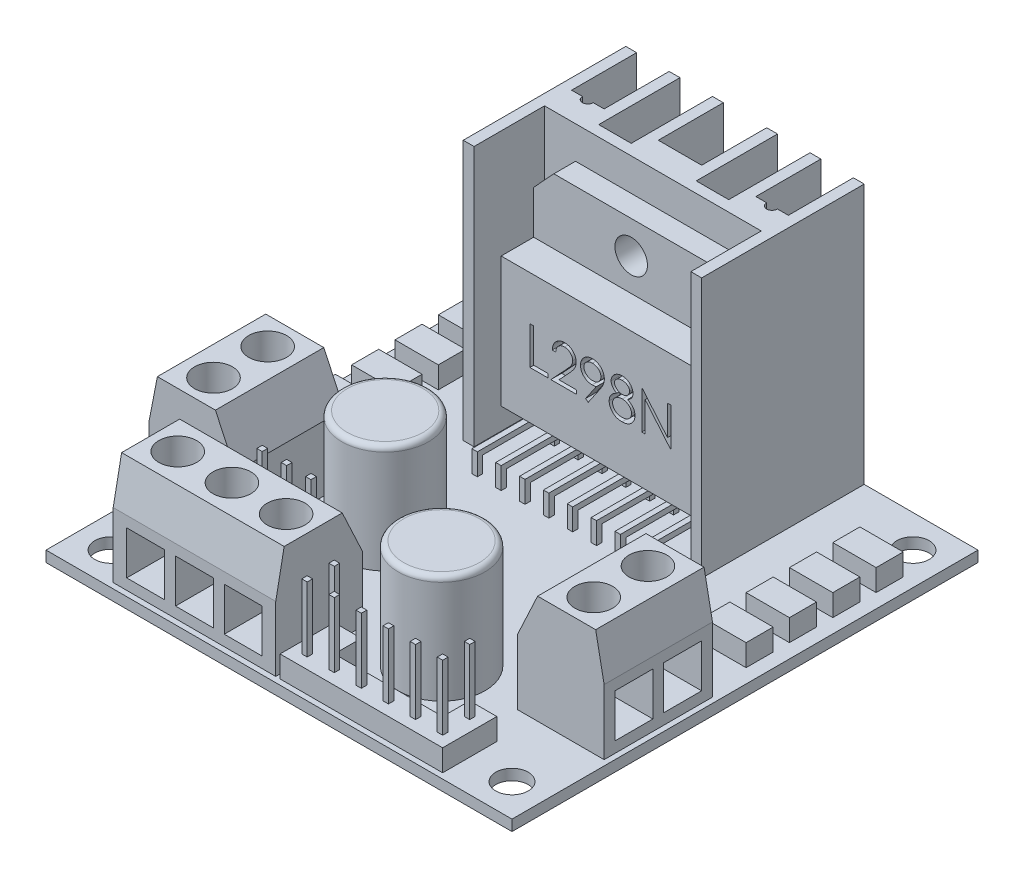
from build123d import *

# Parameters (mm, degrees)
BASE_SKETCH_W             = 43
BASE_SKETCH_H             = 43
BASE_SKETCH_R             = 1.5
BASE_DEPTH                = 1
RADIATOR_DEPTH            = 24
TERMINAL_1_SKETCH_W       = 8
TERMINAL_1_SKETCH_H       = 10
TERMINAL_1_DEPTH          = 10
TERMINAL_2_SKETCH_W       = 15
TERMINAL_2_SKETCH_H       = 8
TERMINAL_2_DEPTH          = 10
CHAMFER_25_SIZE2          = 1.865230633
CHAMFER_25_SIZE           = 4
CHAMFER_10_SIZE           = 4
CHAMFER_10_SIZE2          = 0.777521237
CHAMFER_10_PART_2_SIZE    = 4
CHAMFER_10_PART_2_SIZE2   = 0.777521237
CHAMFER_10_PART_3_SIZE    = 4
CHAMFER_10_PART_3_SIZE2   = 0.777521237
DIODE_SKETCH_W            = 4
DIODE_SKETCH_H            = 2.5
DIODE_DEPTH               = 2
CAPACITOR_SKETCH_R        = 4
CAPACITOR_DEPTH           = 10
FILLET_2_R                = 0.5
RAIL_6_DEPTH              = 2
RAIL_3_SKETCH_W           = 6.6
RAIL_3_SKETCH_H           = 2.2
RAIL_3_DEPTH              = 2
JACK_6_SKETCH_W           = 0.5
JACK_6_SKETCH_H           = 0.5
JACK_6_DEPTH              = 6
JACK_3_SKETCH_W           = 0.5
JACK_3_SKETCH_H           = 0.5
JACK_3_DEPTH              = 6
L298_IC_DEPTH             = 5
L298_CUT_SKETCH_W         = 18
L298_CUT_SKETCH_H         = 6
L298_CUT_DEPTH            = 3
L298_LEG_1_SKETCH_W       = 0.5
L298_LEG_1_SKETCH_H       = 0.5
L298_LEG_1_DEPTH          = 1.5
L298_LEG_2_SKETCH_W       = 0.5
L298_LEG_2_SKETCH_H       = 0.5
L298_LEG_2_DEPTH          = 6
L298_LEG_3_SKETCH_W       = 0.5
L298_LEG_3_SKETCH_H       = 0.5
L298_LEG_3_DEPTH          = 2.5
BOSS_EXTRUDE1_REACH       = 26
SKETCH1_W                 = 0.5
SKETCH1_H                 = 0.5
L298_NAME_DEPTH           = 1
ROLE_SKETCH_R             = 1.5
ROLE_DEPTH                = 11.5
ROLE_TERMINAL_1A_SKETCH_W = 3.5
ROLE_TERMINAL_1A_SKETCH_H = 4
ROLE_TERMINAL_1A_DEPTH    = 4
ROLE_TERMINAL_1B_SKETCH_W = 3.5
ROLE_TERMINAL_1B_SKETCH_H = 4
ROLE_TERMINAL_1B_DEPTH    = 3.5
ROLE_TERMINAL_2_SKETCH_W  = 3.5
ROLE_TERMINAL_2_SKETCH_H  = 4
ROLE_TERMINAL_2_DEPTH     = 3.5
SKETCH4_R                 = 1.75
ROLE_TERMINAL_3_DEPTH     = 3.5


with BuildPart() as part:
    # base_sketch → base (new body)
    with BuildSketch(Plane(origin=(0, 0, 0), x_dir=(1, 0, 0), z_dir=(0, 1, 0))):
        with Locations((-21.5, -21.5)):
            Rectangle(BASE_SKETCH_W, BASE_SKETCH_H)
        with Locations((-40, -3)):
            Circle(BASE_SKETCH_R, mode=Mode.SUBTRACT)
        with Locations((-3, -3)):
            Circle(BASE_SKETCH_R, mode=Mode.SUBTRACT)
        with Locations((-40, -40)):
            Circle(BASE_SKETCH_R, mode=Mode.SUBTRACT)
        with Locations((-3, -40)):
            Circle(BASE_SKETCH_R, mode=Mode.SUBTRACT)
    extrude(amount=BASE_DEPTH)

    # radiator_sketch → radiator (add)
    with BuildSketch(Plane(origin=(0, 1, 0), x_dir=(-1, 0, 0), z_dir=(0, 1, 0))):
        with BuildLine():
            Line((10.5, 0), (10.5, 15))
            Line((10.5, 15), (11.5, 15))
            Line((11.5, 15), (11.5, 8.5))
            Line((11.5, 8.5), (31.5, 8.5))
            Line((31.5, 8.5), (31.5, 15))
            Line((31.5, 15), (32.5, 15))
            Line((32.5, 15), (32.5, 0))
            Line((32.5, 0), (31.5, 0))
            Line((31.5, 0), (31.5, 6))
            Line((31.5, 6), (30.5, 6))
            ThreePointArc((30.5, 6), (30, 6.5), (29.5, 6))
            Line((29.5, 6), (28.5, 6))
            Line((28.5, 6), (28.5, 0))
            Line((28.5, 0), (27.5, 0))
            Line((27.5, 0), (27.5, 7.5))
            Line((27.5, 7.5), (24.5, 7.5))
            Line((24.5, 7.5), (24.5, 0))
            Line((24.5, 0), (23.5, 0))
            Line((23.5, 0), (23.5, 6))
            Line((23.5, 6), (19.5, 6))
            Line((19.5, 6), (19.5, 0))
            Line((19.5, 0), (18.5, 0))
            Line((18.5, 0), (18.5, 7.5))
            Line((18.5, 7.5), (15.5, 7.5))
            Line((15.5, 7.5), (15.5, 0))
            Line((15.5, 0), (14.5, 0))
            Line((14.5, 0), (14.5, 6))
            Line((14.5, 6), (13.5, 6))
            ThreePointArc((13.5, 6), (13, 6.5), (12.5, 6))
            Line((12.5, 6), (11.5, 6))
            Line((11.5, 6), (11.5, 0))
            Line((11.5, 0), (10.5, 0))
        make_face()
    extrude(amount=RADIATOR_DEPTH)

    # terminal_1_sketch → terminal_1 (add)
    with BuildSketch(Plane(origin=(0, 1, 0), x_dir=(-1, 0, 0), z_dir=(0, 1, 0))):
        with Locations((4.5, 29)):
            Rectangle(TERMINAL_1_SKETCH_W, TERMINAL_1_SKETCH_H)
        with Locations((38.5, 29)):
            Rectangle(TERMINAL_1_SKETCH_W, TERMINAL_1_SKETCH_H)
    extrude(amount=TERMINAL_1_DEPTH)

    # terminal_2_sketch → terminal_2 (add)
    with BuildSketch(Plane(origin=(0, 1, 0), x_dir=(-1, 0, 0), z_dir=(0, 1, 0))):
        with Locations((29.8, 38.5)):
            Rectangle(TERMINAL_2_SKETCH_W, TERMINAL_2_SKETCH_H)
    extrude(amount=TERMINAL_2_DEPTH)

    # chamfer_25
    chamfer_25_edges = [part.edges().sort_by_distance(p)[0] for p in [
        (-34.5, 11, 29),
        (-8.5, 11, 29),
        (-29.8, 11, 34.5),
    ]]
    chamfer(chamfer_25_edges, length=CHAMFER_25_SIZE, length2=CHAMFER_25_SIZE2)

    # chamfer_10
    chamfer_10_edges = [part.edges().sort_by_distance(p)[0] for p in [
        (-42.5, 11, 29),
    ]]
    chamfer_10_side = [part.faces().sort_by_distance(p)[0] for p in [
        (-42.5, 6, 29),
    ]]
    chamfer(chamfer_10_edges, length=CHAMFER_10_SIZE, length2=CHAMFER_10_SIZE2, reference=chamfer_10_side[0])

    # chamfer_10 part 2
    chamfer_10_part_2_edges = [part.edges().sort_by_distance(p)[0] for p in [
        (-0.5, 11, 29),
    ]]
    chamfer_10_part_2_side = [part.faces().sort_by_distance(p)[0] for p in [
        (-0.5, 6, 29),
    ]]
    chamfer(chamfer_10_part_2_edges, length=CHAMFER_10_PART_2_SIZE, length2=CHAMFER_10_PART_2_SIZE2, reference=chamfer_10_part_2_side[0])

    # chamfer_10 part 3
    chamfer_10_part_3_edges = [part.edges().sort_by_distance(p)[0] for p in [
        (-29.8, 11, 42.5),
    ]]
    chamfer_10_part_3_side = [part.faces().sort_by_distance(p)[0] for p in [
        (-29.8, 6, 42.5),
    ]]
    chamfer(chamfer_10_part_3_edges, length=CHAMFER_10_PART_3_SIZE, length2=CHAMFER_10_PART_3_SIZE2, reference=chamfer_10_part_3_side[0])

    # diode_sketch → diode (add)
    with BuildSketch(Plane(origin=(0, 1, 0), x_dir=(-1, 0, 0), z_dir=(0, 1, 0))):
        with Locations((3.3, 10.85)):
            Rectangle(DIODE_SKETCH_W, DIODE_SKETCH_H)
        with Locations((3.3, 6.85)):
            Rectangle(DIODE_SKETCH_W, DIODE_SKETCH_H)
        with Locations((3.3, 14.85)):
            Rectangle(DIODE_SKETCH_W, DIODE_SKETCH_H)
        with Locations((3.3, 18.85)):
            Rectangle(DIODE_SKETCH_W, DIODE_SKETCH_H)
        with Locations((39.7, 18.85)):
            Rectangle(DIODE_SKETCH_W, DIODE_SKETCH_H)
        with Locations((39.7, 14.85)):
            Rectangle(DIODE_SKETCH_W, DIODE_SKETCH_H)
        with Locations((39.7, 10.85)):
            Rectangle(DIODE_SKETCH_W, DIODE_SKETCH_H)
        with Locations((39.7, 6.85)):
            Rectangle(DIODE_SKETCH_W, DIODE_SKETCH_H)
    extrude(amount=DIODE_DEPTH)

    # capacitor_sketch → capacitor (add)
    with BuildSketch(Plane(origin=(0, 1, 0), x_dir=(-1, 0, 0), z_dir=(0, 1, 0))):
        with Locations((28.5, 26.2)):
            Circle(CAPACITOR_SKETCH_R)
        with Locations((15.5, 34)):
            Circle(CAPACITOR_SKETCH_R)
    extrude(amount=CAPACITOR_DEPTH)

    # fillet 2
    fillet_2_edges = [part.edges().sort_by_distance(p)[0] for p in [
        (-24.5, 11, 26.2),
        (-11.5, 11, 34),
    ]]
    fillet(fillet_2_edges, radius=FILLET_2_R)

    # rail_6_sketch → rail_6 (add)
    with BuildSketch(Plane(origin=(0, 1, 0), x_dir=(-1, 0, 0), z_dir=(0, 1, 0))):
        Polygon((21.9, 42.5), (6.9, 42.5), (6.9, 37.5), (9.4, 37.5), (9.4, 40), (19.4, 40), (19.4, 37.5), (21.9, 37.5), align=None)
    extrude(amount=RAIL_6_DEPTH)

    # rail_3_sketch → rail_3 (add)
    with BuildSketch(Plane(origin=(0, 1, 0), x_dir=(-1, 0, 0), z_dir=(0, 1, 0))):
        with Locations((30.9, 32.9)):
            Rectangle(RAIL_3_SKETCH_W, RAIL_3_SKETCH_H)
    extrude(amount=RAIL_3_DEPTH)

    # jack_6_sketch → jack_6 (add)
    with BuildSketch(Plane(origin=(0, 3, 0), x_dir=(-1, 0, 0), z_dir=(0, 1, 0))):
        with Locations((18.15, 41.25)):
            Rectangle(JACK_6_SKETCH_W, JACK_6_SKETCH_H)
        with Locations((20.65, 41.25)):
            Rectangle(JACK_6_SKETCH_W, JACK_6_SKETCH_H)
        with Locations((15.65, 41.25)):
            Rectangle(JACK_6_SKETCH_W, JACK_6_SKETCH_H)
        with Locations((13.15, 41.25)):
            Rectangle(JACK_6_SKETCH_W, JACK_6_SKETCH_H)
        with Locations((10.65, 41.25)):
            Rectangle(JACK_6_SKETCH_W, JACK_6_SKETCH_H)
        with Locations((8.15, 41.25)):
            Rectangle(JACK_6_SKETCH_W, JACK_6_SKETCH_H)
        with Locations((20.65, 38.75)):
            Rectangle(JACK_6_SKETCH_W, JACK_6_SKETCH_H)
        with Locations((8.15, 38.75)):
            Rectangle(JACK_6_SKETCH_W, JACK_6_SKETCH_H)
    extrude(amount=JACK_6_DEPTH)

    # jack_3_sketch → jack_3 (add)
    with BuildSketch(Plane(origin=(0, 3, 0), x_dir=(1, 0, 0), z_dir=(0, 1, 0))):
        with Locations((-30.9, -32.9)):
            Rectangle(JACK_3_SKETCH_W, JACK_3_SKETCH_H)
        with Locations((-33.15, -32.9)):
            Rectangle(JACK_3_SKETCH_W, JACK_3_SKETCH_H)
        with Locations((-28.65, -32.9)):
            Rectangle(JACK_3_SKETCH_W, JACK_3_SKETCH_H)
    extrude(amount=JACK_3_DEPTH)

    # L298_sketch → L298_IC (add)
    with BuildSketch(Plane.XY.offset(8.5)):
        Polygon((-30.5, 19.987466442), (-30.5, 4), (-12.5, 4), (-12.5, 19.987466442), (-14.362533558, 22), (-28.637466442, 22), align=None)
    extrude(amount=L298_IC_DEPTH)

    # L298_cut_sketch → L298_cut (cut)
    with BuildSketch(Plane.XY.offset(13.5)):
        with Locations((-21.5, 19)):
            Rectangle(L298_CUT_SKETCH_W, L298_CUT_SKETCH_H)
    extrude(amount=-L298_CUT_DEPTH, mode=Mode.SUBTRACT)

    # L298_leg_1_sketch → L298_leg_1 (add)
    with BuildSketch(Plane.XZ.offset(-4)):
        with Locations((-28.1, 11)):
            Rectangle(L298_LEG_1_SKETCH_W, L298_LEG_1_SKETCH_H)
        with Locations((-29.2, 11)):
            Rectangle(L298_LEG_1_SKETCH_W, L298_LEG_1_SKETCH_H)
        with Locations((-27, 11)):
            Rectangle(L298_LEG_1_SKETCH_W, L298_LEG_1_SKETCH_H)
        with Locations((-25.9, 11)):
            Rectangle(L298_LEG_1_SKETCH_W, L298_LEG_1_SKETCH_H)
        with Locations((-24.8, 11)):
            Rectangle(L298_LEG_1_SKETCH_W, L298_LEG_1_SKETCH_H)
        with Locations((-23.7, 11)):
            Rectangle(L298_LEG_1_SKETCH_W, L298_LEG_1_SKETCH_H)
        with Locations((-22.6, 11)):
            Rectangle(L298_LEG_1_SKETCH_W, L298_LEG_1_SKETCH_H)
        with Locations((-21.5, 11)):
            Rectangle(L298_LEG_1_SKETCH_W, L298_LEG_1_SKETCH_H)
        with Locations((-20.4, 11)):
            Rectangle(L298_LEG_1_SKETCH_W, L298_LEG_1_SKETCH_H)
        with Locations((-19.3, 11)):
            Rectangle(L298_LEG_1_SKETCH_W, L298_LEG_1_SKETCH_H)
        with Locations((-18.2, 11)):
            Rectangle(L298_LEG_1_SKETCH_W, L298_LEG_1_SKETCH_H)
        with Locations((-17.1, 11)):
            Rectangle(L298_LEG_1_SKETCH_W, L298_LEG_1_SKETCH_H)
        with Locations((-16, 11)):
            Rectangle(L298_LEG_1_SKETCH_W, L298_LEG_1_SKETCH_H)
        with Locations((-14.9, 11)):
            Rectangle(L298_LEG_1_SKETCH_W, L298_LEG_1_SKETCH_H)
        with Locations((-13.8, 11)):
            Rectangle(L298_LEG_1_SKETCH_W, L298_LEG_1_SKETCH_H)
    extrude(amount=L298_LEG_1_DEPTH)

    # L298_leg_2_sketch → L298_leg_2 (add)
    with BuildSketch(Plane.XY.offset(11.25)):
        with Locations((-13.8, 2.75)):
            Rectangle(L298_LEG_2_SKETCH_W, L298_LEG_2_SKETCH_H)
        with Locations((-16, 2.75)):
            Rectangle(L298_LEG_2_SKETCH_W, L298_LEG_2_SKETCH_H)
        with Locations((-18.2, 2.75)):
            Rectangle(L298_LEG_2_SKETCH_W, L298_LEG_2_SKETCH_H)
        with Locations((-20.4, 2.75)):
            Rectangle(L298_LEG_2_SKETCH_W, L298_LEG_2_SKETCH_H)
        with Locations((-22.6, 2.75)):
            Rectangle(L298_LEG_2_SKETCH_W, L298_LEG_2_SKETCH_H)
        with Locations((-24.8, 2.75)):
            Rectangle(L298_LEG_2_SKETCH_W, L298_LEG_2_SKETCH_H)
        with Locations((-27, 2.75)):
            Rectangle(L298_LEG_2_SKETCH_W, L298_LEG_2_SKETCH_H)
        with Locations((-29.2, 2.75)):
            Rectangle(L298_LEG_2_SKETCH_W, L298_LEG_2_SKETCH_H)
    extrude(amount=L298_LEG_2_DEPTH)

    # L298_leg_3_sketch → L298_leg_3 (add)
    with BuildSketch(Plane.XZ):
        with Locations((-29.2, 17)):
            Rectangle(L298_LEG_3_SKETCH_W, L298_LEG_3_SKETCH_H)
        with Locations((-27, 17)):
            Rectangle(L298_LEG_3_SKETCH_W, L298_LEG_3_SKETCH_H)
        with Locations((-24.8, 17)):
            Rectangle(L298_LEG_3_SKETCH_W, L298_LEG_3_SKETCH_H)
        with Locations((-22.6, 17)):
            Rectangle(L298_LEG_3_SKETCH_W, L298_LEG_3_SKETCH_H)
        with Locations((-20.4, 17)):
            Rectangle(L298_LEG_3_SKETCH_W, L298_LEG_3_SKETCH_H)
        with Locations((-18.2, 17)):
            Rectangle(L298_LEG_3_SKETCH_W, L298_LEG_3_SKETCH_H)
        with Locations((-16, 17)):
            Rectangle(L298_LEG_3_SKETCH_W, L298_LEG_3_SKETCH_H)
        with Locations((-13.8, 17)):
            Rectangle(L298_LEG_3_SKETCH_W, L298_LEG_3_SKETCH_H)
    extrude(amount=-L298_LEG_3_DEPTH)

    # Sketch1 → Boss-Extrude1 (add, up to next)
    with BuildSketch(Plane(origin=(0, 1, 0), x_dir=(1, 0, 0), z_dir=(0, 1, 0)), mode=Mode.PRIVATE) as boss_extrude1_sk1:
        with Locations((-14.9, -11)):
            Rectangle(SKETCH1_W, SKETCH1_H)
    boss_extrude1_tool1 = extrude(boss_extrude1_sk1.sketch, amount=BOSS_EXTRUDE1_REACH, mode=Mode.PRIVATE) - part.part
    add(boss_extrude1_tool1.solids().sort_by_distance((-14.9, 1, 11))[0])
    # Sketch1 → Boss-Extrude1 (add, up to next)
    with BuildSketch(Plane(origin=(0, 1, 0), x_dir=(1, 0, 0), z_dir=(0, 1, 0)), mode=Mode.PRIVATE) as boss_extrude1_sk2:
        with Locations((-17.1, -11)):
            Rectangle(SKETCH1_W, SKETCH1_H)
    boss_extrude1_tool2 = extrude(boss_extrude1_sk2.sketch, amount=BOSS_EXTRUDE1_REACH, mode=Mode.PRIVATE) - part.part
    add(boss_extrude1_tool2.solids().sort_by_distance((-17.1, 1, 11))[0])
    # Sketch1 → Boss-Extrude1 (add, up to next)
    with BuildSketch(Plane(origin=(0, 1, 0), x_dir=(1, 0, 0), z_dir=(0, 1, 0)), mode=Mode.PRIVATE) as boss_extrude1_sk3:
        with Locations((-19.3, -11)):
            Rectangle(SKETCH1_W, SKETCH1_H)
    boss_extrude1_tool3 = extrude(boss_extrude1_sk3.sketch, amount=BOSS_EXTRUDE1_REACH, mode=Mode.PRIVATE) - part.part
    add(boss_extrude1_tool3.solids().sort_by_distance((-19.3, 1, 11))[0])
    # Sketch1 → Boss-Extrude1 (add, up to next)
    with BuildSketch(Plane(origin=(0, 1, 0), x_dir=(1, 0, 0), z_dir=(0, 1, 0)), mode=Mode.PRIVATE) as boss_extrude1_sk4:
        with Locations((-21.5, -11)):
            Rectangle(SKETCH1_W, SKETCH1_H)
    boss_extrude1_tool4 = extrude(boss_extrude1_sk4.sketch, amount=BOSS_EXTRUDE1_REACH, mode=Mode.PRIVATE) - part.part
    add(boss_extrude1_tool4.solids().sort_by_distance((-21.5, 1, 11))[0])
    # Sketch1 → Boss-Extrude1 (add, up to next)
    with BuildSketch(Plane(origin=(0, 1, 0), x_dir=(1, 0, 0), z_dir=(0, 1, 0)), mode=Mode.PRIVATE) as boss_extrude1_sk5:
        with Locations((-23.7, -11)):
            Rectangle(SKETCH1_W, SKETCH1_H)
    boss_extrude1_tool5 = extrude(boss_extrude1_sk5.sketch, amount=BOSS_EXTRUDE1_REACH, mode=Mode.PRIVATE) - part.part
    add(boss_extrude1_tool5.solids().sort_by_distance((-23.7, 1, 11))[0])
    # Sketch1 → Boss-Extrude1 (add, up to next)
    with BuildSketch(Plane(origin=(0, 1, 0), x_dir=(1, 0, 0), z_dir=(0, 1, 0)), mode=Mode.PRIVATE) as boss_extrude1_sk6:
        with Locations((-25.9, -11)):
            Rectangle(SKETCH1_W, SKETCH1_H)
    boss_extrude1_tool6 = extrude(boss_extrude1_sk6.sketch, amount=BOSS_EXTRUDE1_REACH, mode=Mode.PRIVATE) - part.part
    add(boss_extrude1_tool6.solids().sort_by_distance((-25.9, 1, 11))[0])
    # Sketch1 → Boss-Extrude1 (add, up to next)
    with BuildSketch(Plane(origin=(0, 1, 0), x_dir=(1, 0, 0), z_dir=(0, 1, 0)), mode=Mode.PRIVATE) as boss_extrude1_sk7:
        with Locations((-28.1, -11)):
            Rectangle(SKETCH1_W, SKETCH1_H)
    boss_extrude1_tool7 = extrude(boss_extrude1_sk7.sketch, amount=BOSS_EXTRUDE1_REACH, mode=Mode.PRIVATE) - part.part
    add(boss_extrude1_tool7.solids().sort_by_distance((-28.1, 1, 11))[0])

    # L298_name_sketch → L298_name (cut)
    with BuildSketch(Plane.XY.offset(13.5)):
        Polygon((-27.846931762, 11.915865738), (-27.532829198, 11.915865738), (-27.532829198, 8.774840097), (-26.186675351, 8.774840097), (-26.186675351, 8.415865738), (-27.846931762, 8.415865738), align=None)
        with BuildLine():
            Line((-25.468726633, 10.838942661), (-25.782829198, 10.838942661))
            add(Edge.make_bspline(
                [(-25.782829198, 10.838942661), (-25.780782045, 10.880613549), (-25.77676149, 10.962454063), (-25.757933201, 11.08177797), (-25.730992324, 11.195832768), (-25.69290087, 11.303702682), (-25.645594592, 11.40634149), (-25.588864565, 11.503341505), (-25.521670714, 11.594332694), (-25.44546398, 11.678471537), (-25.362695341, 11.755659108), (-25.273389402, 11.822314351), (-25.179544374, 11.878632022), (-25.081444976, 11.925713264), (-24.977984412, 11.96105311), (-24.870101554, 11.98727475), (-24.757322418, 12.003051095), (-24.680482396, 12.004746881), (-24.641402915, 12.005609328)],
                knots=[0, 0, 0, 0, 0.000125083, 0.00024566, 0.000361805, 0.000476223, 0.000588214, 0.000700404, 0.000812728, 0.00092691, 0.001040529, 0.001151727, 0.001260545, 0.001368429, 0.001477521, 0.001587884, 0.001701119, 0.00181831, 0.00181831, 0.00181831, 0.00181831], degree=3))
            add(Edge.make_bspline(
                [(-24.641402915, 12.005609328), (-24.603024841, 12.004710871), (-24.527613297, 12.002945436), (-24.417551282, 11.987784407), (-24.312773988, 11.964038815), (-24.213486221, 11.930723399), (-24.120480157, 11.885938972), (-24.033057112, 11.832141433), (-23.950176301, 11.769921602), (-23.875569518, 11.696667788), (-23.807061439, 11.618465404), (-23.747959183, 11.5349775), (-23.69734602, 11.448748214), (-23.65515834, 11.359120013), (-23.624102201, 11.265248985), (-23.600523993, 11.168501782), (-23.587196579, 11.067876971), (-23.585151156, 10.999770415), (-23.584111249, 10.965144584)],
                knots=[0, 0, 0, 0, 0.000115089, 0.000226145, 0.000332614, 0.000437044, 0.000539592, 0.000641561, 0.000744629, 0.00084975, 0.000954621, 0.001056175, 0.001156101, 0.001254284, 0.001352726, 0.001452208, 0.001552655, 0.001656537, 0.001656537, 0.001656537, 0.001656537], degree=3))
            add(Edge.make_bspline(
                [(-23.584111249, 10.965144584), (-23.585804512, 10.916396749), (-23.589161323, 10.819756536), (-23.6178757, 10.677741673), (-23.662722211, 10.540148254), (-23.716719568, 10.429410952), (-23.771192012, 10.340177458), (-23.820279519, 10.266708753), (-23.87774433, 10.187603285), (-23.944422828, 10.103125947), (-24.0189357, 10.012615042), (-24.101957864, 9.916125247), (-24.194081346, 9.814653477), (-24.258739846, 9.745347876), (-24.292244262, 9.709435449)],
                knots=[0, 0, 0, 0, 0.000146118, 0.000289672, 0.0004329, 0.00057934, 0.000657978, 0.000746456, 0.000844345, 0.000951219, 0.001069268, 0.00119604, 0.001333047, 0.001480391, 0.001480391, 0.001480391, 0.001480391], degree=3))
            Line((-24.292244262, 9.709435449), (-25.167945383, 8.774840097))
            Line((-25.167945383, 8.774840097), (-23.539239454, 8.774840097))
            Line((-23.539239454, 8.774840097), (-23.539239454, 8.415865738))
            Line((-23.539239454, 8.415865738), (-25.917444582, 8.415865738))
            Line((-25.917444582, 8.415865738), (-24.560072787, 9.864383366))
            add(Edge.make_bspline(
                [(-24.560072787, 9.864383366), (-24.5270249, 9.898881673), (-24.463546673, 9.965145859), (-24.373764097, 10.061888819), (-24.293125108, 10.15163836), (-24.221107715, 10.234224909), (-24.15927421, 10.310856476), (-24.104401978, 10.37905118), (-24.060436387, 10.44180563), (-24.012720991, 10.514546244), (-23.96650701, 10.603358561), (-23.926794654, 10.711892251), (-23.902579806, 10.823619503), (-23.89967497, 10.89912154), (-23.898213813, 10.937099712)],
                knots=[0, 0, 0, 0, 0.000143319, 0.000275286, 0.00039593, 0.000505287, 0.000603949, 0.000691331, 0.000767782, 0.00083371, 0.000952247, 0.001067137, 0.001179618, 0.001293462, 0.001293462, 0.001293462, 0.001293462], degree=3))
            add(Edge.make_bspline(
                [(-23.898213813, 10.937099712), (-23.898849555, 10.960981111), (-23.900102481, 11.008046761), (-23.911160179, 11.07705252), (-23.927870685, 11.143617334), (-23.951815943, 11.207945953), (-23.983422683, 11.269391605), (-24.021896063, 11.328029085), (-24.066286126, 11.38471805), (-24.117637396, 11.437871349), (-24.174048915, 11.486552554), (-24.233643165, 11.529676639), (-24.296693269, 11.56571575), (-24.362933391, 11.595259247), (-24.432178861, 11.618434629), (-24.504563606, 11.634493208), (-24.579887622, 11.644575692), (-24.631321118, 11.645939864), (-24.657528717, 11.646634969)],
                knots=[0, 0, 0, 0, 7.16e-05, 0.00014111, 0.00020913, 0.00027724, 0.000346538, 0.000415963, 0.000487357, 0.000562233, 0.000637292, 0.000710646, 0.000782564, 0.000854749, 0.000927915, 0.001001225, 0.001076884, 0.001155488, 0.001155488, 0.001155488, 0.001155488], degree=3))
            add(Edge.make_bspline(
                [(-24.657528717, 11.646634969), (-24.68489955, 11.645919936), (-24.738651346, 11.644515731), (-24.817570379, 11.634693067), (-24.892856156, 11.617747227), (-24.964698059, 11.594570552), (-25.033217645, 11.565112004), (-25.098081689, 11.528420259), (-25.159144578, 11.484636766), (-25.216521102, 11.434996209), (-25.269385081, 11.379728608), (-25.315831957, 11.318118645), (-25.356415971, 11.25129123), (-25.391825204, 11.179426679), (-25.420580894, 11.101872899), (-25.442554045, 11.018905194), (-25.459940891, 10.930883813), (-25.465749412, 10.870098728), (-25.468726633, 10.838942661)],
                knots=[0, 0, 0, 0, 8.2106e-05, 0.000161243, 0.000238127, 0.000313291, 0.000387401, 0.000461495, 0.000536397, 0.000612445, 0.000688819, 0.000765383, 0.000843422, 0.000923066, 0.001005373, 0.001091093, 0.001180334, 0.001274175, 0.001274175, 0.001274175, 0.001274175], degree=3))
        make_face()
        with BuildLine():
            Line((-22.462316377, 8.326122148), (-22.71331798, 8.500701475))
            Line((-22.71331798, 8.500701475), (-21.740160928, 9.923277597))
            add(Edge.make_bspline(
                [(-21.740160928, 9.923277597), (-21.802251664, 9.915684534), (-21.924511784, 9.900733369), (-22.047648886, 9.897986714), (-22.108249871, 9.896634969)],
                knots=[0, 0, 0, 0, 0.000187529, 0.000369255, 0.000369255, 0.000369255, 0.000369255], degree=3))
            add(Edge.make_bspline(
                [(-22.108249871, 9.896634969), (-22.144991918, 9.897576045), (-22.217113345, 9.899423296), (-22.323144998, 9.914065104), (-22.425030558, 9.936615232), (-22.522499914, 9.970263987), (-22.615919419, 10.012082196), (-22.705085133, 10.06393921), (-22.789877023, 10.124945501), (-22.869384433, 10.194778493), (-22.941696172, 10.271456545), (-23.00611947, 10.352612188), (-23.059660602, 10.439188159), (-23.104137187, 10.529418378), (-23.137867641, 10.624599729), (-23.162430178, 10.723649129), (-23.177552532, 10.827260771), (-23.179351628, 10.897785902), (-23.180265095, 10.933594103)],
                knots=[0, 0, 0, 0, 0.000110185, 0.000216284, 0.000320547, 0.000422759, 0.000525058, 0.000627155, 0.000731643, 0.000837964, 0.0009441, 0.00104747, 0.001148247, 0.001248901, 0.001348697, 0.001450555, 0.001554666, 0.00166205, 0.00166205, 0.00166205, 0.00166205], degree=3))
            add(Edge.make_bspline(
                [(-23.180265095, 10.933594103), (-23.17853066, 10.982562756), (-23.175126317, 11.078678288), (-23.147727799, 11.219112057), (-23.10266746, 11.3518986), (-23.039839083, 11.476688794), (-22.960704362, 11.591687533), (-22.865595772, 11.695296142), (-22.755091807, 11.786040996), (-22.631709788, 11.864045074), (-22.498356768, 11.926780071), (-22.358688109, 11.973019371), (-22.213773989, 12.000218119), (-22.115606319, 12.00380398), (-22.066182563, 12.005609328)],
                knots=[0, 0, 0, 0, 0.000146818, 0.000288173, 0.000427413, 0.000566316, 0.000705952, 0.000844895, 0.000986821, 0.001133677, 0.001281714, 0.001427825, 0.001574003, 0.00172222, 0.00172222, 0.00172222, 0.00172222], degree=3))
            add(Edge.make_bspline(
                [(-22.066182563, 12.005609328), (-22.017694143, 12.003779165), (-21.921885596, 12.000162935), (-21.78099659, 11.973678966), (-21.646055573, 11.929042293), (-21.517810586, 11.867357729), (-21.399071174, 11.790036822), (-21.292295363, 11.697902298), (-21.199919824, 11.590896771), (-21.122095943, 11.471608281), (-21.059625903, 11.343441299), (-21.01455362, 11.209657377), (-20.986807981, 11.071218656), (-20.983311654, 10.977424181), (-20.981547146, 10.930088494)],
                knots=[0, 0, 0, 0, 0.000145418, 0.000287333, 0.000428343, 0.000570713, 0.000713061, 0.00085223, 0.000992387, 0.001135706, 0.001278381, 0.001418948, 0.001558239, 0.001700158, 0.001700158, 0.001700158, 0.001700158], degree=3))
            add(Edge.make_bspline(
                [(-20.981547146, 10.930088494), (-20.982725555, 10.893344727), (-20.985115663, 10.818819186), (-21.00185197, 10.705588844), (-21.030272155, 10.590137614), (-21.062523854, 10.492416018), (-21.093656022, 10.411707569), (-21.122957153, 10.347955989), (-21.155469307, 10.280854725), (-21.193388072, 10.211107387), (-21.234150369, 10.137824852), (-21.280209646, 10.061742137), (-21.330515217, 9.982757144), (-21.366344937, 9.929510056), (-21.384692178, 9.902243943)],
                knots=[0, 0, 0, 0, 0.000110219, 0.000223552, 0.000342587, 0.000466527, 0.000532018, 0.000601997, 0.000676938, 0.00075567, 0.000840114, 0.000928491, 0.001022434, 0.001121023, 0.001121023, 0.001121023, 0.001121023], degree=3))
            Line((-21.384692178, 9.902243943), (-22.462316377, 8.326122148))
        make_face()
        with BuildLine():
            add(Edge.make_bspline(
                [(-22.050056762, 10.255609328), (-22.022222748, 10.256369711), (-21.968039384, 10.25784992), (-21.888662085, 10.266859162), (-21.813737882, 10.282833148), (-21.743066633, 10.30575286), (-21.675939731, 10.333409529), (-21.613423403, 10.368621515), (-21.555465327, 10.41063815), (-21.5016774, 10.457848166), (-21.453913401, 10.510298749), (-21.41137037, 10.565195856), (-21.375209802, 10.622780466), (-21.346646525, 10.683773728), (-21.32316195, 10.746690937), (-21.306943938, 10.812545292), (-21.297959605, 10.880993693), (-21.29642803, 10.927492351), (-21.29564971, 10.951122148)],
                knots=[0, 0, 0, 0, 8.3507e-05, 0.00016256, 0.000239294, 0.000312908, 0.000385178, 0.000456751, 0.000527578, 0.000599603, 0.000671055, 0.000740051, 0.000807755, 0.000874553, 0.000941763, 0.001008931, 0.001077548, 0.001148448, 0.001148448, 0.001148448, 0.001148448], degree=3))
            add(Edge.make_bspline(
                [(-21.29564971, 10.951122148), (-21.29631938, 10.974761813), (-21.297639045, 11.021346673), (-21.308226344, 11.089896413), (-21.326851568, 11.155589674), (-21.351842052, 11.218786104), (-21.38476229, 11.278966476), (-21.424265776, 11.336886348), (-21.471198226, 11.392178475), (-21.525200792, 11.443542459), (-21.583435345, 11.490890358), (-21.645495845, 11.532676434), (-21.710870761, 11.567697631), (-21.779161251, 11.5965966), (-21.8505096, 11.619148376), (-21.924873588, 11.635365741), (-22.002628994, 11.644337495), (-22.05541028, 11.64585939), (-22.082308364, 11.646634969)],
                knots=[0, 0, 0, 0, 7.09e-05, 0.000139717, 0.000207422, 0.000275384, 0.000343146, 0.000412766, 0.000485392, 0.000560268, 0.000636041, 0.000710323, 0.000784354, 0.000858188, 0.000932471, 0.001008519, 0.001086179, 0.001166885, 0.001166885, 0.001166885, 0.001166885], degree=3))
            add(Edge.make_bspline(
                [(-22.082308364, 11.646634969), (-22.108972518, 11.645858137), (-22.161287367, 11.644334), (-22.238351526, 11.635382794), (-22.312212694, 11.61903931), (-22.383354314, 11.596607046), (-22.451642775, 11.567695475), (-22.517014608, 11.532674599), (-22.579089624, 11.490899977), (-22.637268345, 11.443505204), (-22.691366267, 11.392417558), (-22.737491796, 11.336644129), (-22.777085688, 11.278996605), (-22.809960691, 11.218778097), (-22.834963208, 11.155591811), (-22.85358521, 11.089895834), (-22.864173375, 11.021346824), (-22.865492922, 10.974761864), (-22.866162531, 10.951122148)],
                knots=[0, 0, 0, 0, 8.0005e-05, 0.000156969, 0.000232332, 0.000306614, 0.000380449, 0.000454479, 0.000528762, 0.000604535, 0.000679411, 0.000751586, 0.000821205, 0.000888968, 0.00095693, 0.001024634, 0.001093451, 0.001164351, 0.001164351, 0.001164351, 0.001164351], degree=3))
            add(Edge.make_bspline(
                [(-22.866162531, 10.951122148), (-22.865556605, 10.927473949), (-22.864361608, 10.880835373), (-22.852833818, 10.81230898), (-22.833555538, 10.746620786), (-22.807736147, 10.683132079), (-22.773734557, 10.622460221), (-22.732010709, 10.564892859), (-22.683105163, 10.509777409), (-22.627671676, 10.457970197), (-22.567003515, 10.410418022), (-22.502206769, 10.36888764), (-22.434396932, 10.333815195), (-22.363335301, 10.305673811), (-22.289548501, 10.283062148), (-22.21237337, 10.266888603), (-22.132065132, 10.257936336), (-22.07765515, 10.256392439), (-22.050056762, 10.255609328)],
                knots=[0, 0, 0, 0, 7.09e-05, 0.000139828, 0.000207725, 0.00027595, 0.000345002, 0.000415829, 0.000488844, 0.000565728, 0.000643147, 0.000719775, 0.000796287, 0.0008718, 0.000948761, 0.001027552, 0.001107998, 0.001190805, 0.001190805, 0.001190805, 0.001190805], degree=3))
        make_face(mode=Mode.SUBTRACT)
        with BuildLine():
            add(Edge.make_bspline(
                [(-18.831206601, 10.365685449), (-18.802558054, 10.350747493), (-18.74668382, 10.321613491), (-18.667106611, 10.274702663), (-18.59438161, 10.225261698), (-18.526491048, 10.175625839), (-18.464627698, 10.123894187), (-18.409483285, 10.069861031), (-18.359695665, 10.014875086), (-18.316268881, 9.958005246), (-18.278072044, 9.899402596), (-18.245059909, 9.838913323), (-18.216842706, 9.77666999), (-18.194479767, 9.71199316), (-18.176057976, 9.645832898), (-18.163382371, 9.577334916), (-18.156565453, 9.506950575), (-18.155276639, 9.459382274), (-18.154624069, 9.435296828)],
                knots=[0, 0, 0, 0, 9.692e-05, 0.000189026, 0.000276921, 0.000360637, 0.000441251, 0.000518597, 0.000592078, 0.000663595, 0.000733021, 0.000801734, 0.000870147, 0.000937778, 0.001006834, 0.001076004, 0.001146466, 0.001218736, 0.001218736, 0.001218736, 0.001218736], degree=3))
            add(Edge.make_bspline(
                [(-18.154624069, 9.435296828), (-18.15539549, 9.401599095), (-18.156922421, 9.334898638), (-18.170222405, 9.236452527), (-18.190135383, 9.140840745), (-18.219214895, 9.048084254), (-18.256928286, 8.958694881), (-18.303405122, 8.872596107), (-18.356016327, 8.788376798), (-18.398268567, 8.736557396), (-18.419648108, 8.710336892)],
                knots=[0, 0, 0, 0, 0.000101049, 0.000200014, 0.00029751, 0.000393751, 0.000491154, 0.000588073, 0.000687071, 0.000788472, 0.000788472, 0.000788472, 0.000788472], degree=3))
            add(Edge.make_bspline(
                [(-18.419648108, 8.710336892), (-18.447484582, 8.679743118), (-18.502813548, 8.618933625), (-18.597596475, 8.539982815), (-18.701618359, 8.473633421), (-18.814476692, 8.419561526), (-18.935869793, 8.377475667), (-19.065771798, 8.347233149), (-19.204435951, 8.32991072), (-19.299741422, 8.327406731), (-19.348634486, 8.326122148)],
                knots=[0, 0, 0, 0, 0.000123978, 0.000246423, 0.000368759, 0.000493253, 0.000620972, 0.000753455, 0.000892683, 0.001039354, 0.001039354, 0.001039354, 0.001039354], degree=3))
            add(Edge.make_bspline(
                [(-19.348634486, 8.326122148), (-19.395647875, 8.327274626), (-19.487131154, 8.329517231), (-19.620289031, 8.344711663), (-19.744412101, 8.371339529), (-19.860222069, 8.407784139), (-19.967020763, 8.455194367), (-20.064503864, 8.514202776), (-20.154077836, 8.582434218), (-20.23302431, 8.661848296), (-20.303112753, 8.746906168), (-20.364680807, 8.834657778), (-20.415854885, 8.925111136), (-20.45918198, 9.016917503), (-20.492350003, 9.111363657), (-20.515322213, 9.20796367), (-20.529911527, 9.306548813), (-20.531852662, 9.373080466), (-20.532829198, 9.406550834)],
                knots=[0, 0, 0, 0, 0.000141037, 0.000274444, 0.00040137, 0.000521327, 0.000638076, 0.000750983, 0.00086247, 0.000975011, 0.001086056, 0.001192834, 0.001296147, 0.001397463, 0.001497025, 0.001595826, 0.001694979, 0.00179536, 0.00179536, 0.00179536, 0.00179536], degree=3))
            add(Edge.make_bspline(
                [(-20.532829198, 9.406550834), (-20.532251316, 9.431110026), (-20.53110922, 9.479647658), (-20.523204371, 9.551356986), (-20.51049591, 9.621153121), (-20.493236453, 9.689293865), (-20.469845427, 9.755283137), (-20.441603294, 9.819433611), (-20.408671341, 9.88181771), (-20.370590176, 9.942776591), (-20.326288152, 10.001456103), (-20.276124502, 10.058852098), (-20.219096634, 10.114073965), (-20.155838975, 10.16779639), (-20.087074435, 10.220972364), (-20.011016905, 10.270728092), (-19.929682637, 10.320586057), (-19.871877231, 10.350394382), (-19.84222423, 10.365685449)],
                knots=[0, 0, 0, 0, 7.3671e-05, 0.0001456, 0.000216149, 0.000286381, 0.000356229, 0.000425923, 0.00049649, 0.000567687, 0.000641305, 0.000716824, 0.000796154, 0.000879197, 0.00096572, 0.001056725, 0.001151716, 0.001251771, 0.001251771, 0.001251771, 0.001251771], degree=3))
            add(Edge.make_bspline(
                [(-19.84222423, 10.365685449), (-19.882815604, 10.387820218), (-19.961411867, 10.430679326), (-20.065481308, 10.509426132), (-20.154871932, 10.594713947), (-20.227126649, 10.688343741), (-20.283998877, 10.787390616), (-20.323017482, 10.891234868), (-20.349413966, 10.997950982), (-20.352028793, 11.070857178), (-20.353342018, 11.107472308)],
                knots=[0, 0, 0, 0, 0.000138535, 0.000268243, 0.000390218, 0.00050816, 0.000621822, 0.000731457, 0.000840134, 0.00094978, 0.00094978, 0.00094978, 0.00094978], degree=3))
            add(Edge.make_bspline(
                [(-20.353342018, 11.107472308), (-20.351706594, 11.144769867), (-20.348419106, 11.219744464), (-20.321835786, 11.331350587), (-20.278515719, 11.440967152), (-20.219594722, 11.548062865), (-20.146207506, 11.64901308), (-20.05816096, 11.739554026), (-19.957557663, 11.818865508), (-19.844899796, 11.885441681), (-19.723663561, 11.93962534), (-19.595747837, 11.977003763), (-19.463381344, 12.001439879), (-19.373283624, 12.004206534), (-19.327600832, 12.005609328)],
                knots=[0, 0, 0, 0, 0.000111795, 0.000224728, 0.000342168, 0.000464543, 0.000590474, 0.000715423, 0.000842224, 0.000973648, 0.001107055, 0.001239485, 0.001372621, 0.001509557, 0.001509557, 0.001509557, 0.001509557], degree=3))
            add(Edge.make_bspline(
                [(-19.327600832, 12.005609328), (-19.283097017, 12.004162985), (-19.195340564, 12.001310961), (-19.066345936, 11.977524083), (-18.942921059, 11.937794563), (-18.82549156, 11.88389734), (-18.716159693, 11.817510399), (-18.619557383, 11.737109525), (-18.534224801, 11.646967974), (-18.463640407, 11.546048371), (-18.405477518, 11.439364177), (-18.364976617, 11.327741656), (-18.339024643, 11.213592597), (-18.335751278, 11.136354593), (-18.334111249, 11.097656603)],
                knots=[0, 0, 0, 0, 0.000133436, 0.000263121, 0.000391946, 0.000521517, 0.000649943, 0.000774455, 0.000897469, 0.001021193, 0.0011429, 0.001260905, 0.001376422, 0.001492413, 0.001492413, 0.001492413, 0.001492413], degree=3))
            add(Edge.make_bspline(
                [(-18.334111249, 11.097656603), (-18.335545809, 11.059679939), (-18.338363205, 10.98509593), (-18.362063145, 10.87636941), (-18.401976458, 10.774547371), (-18.456470621, 10.678474419), (-18.527496109, 10.589892921), (-18.614104842, 10.507676451), (-18.71560632, 10.431149623), (-18.791867206, 10.387963258), (-18.831206601, 10.365685449)],
                knots=[0, 0, 0, 0, 0.000113843, 0.000223582, 0.000331909, 0.000440874, 0.000553657, 0.00067118, 0.000798364, 0.000933876, 0.000933876, 0.000933876, 0.000933876], degree=3))
        make_face()
        with BuildLine():
            add(Edge.make_bspline(
                [(-19.345128877, 11.646634969), (-19.369679683, 11.645983528), (-19.417711794, 11.644709026), (-19.488140465, 11.638050389), (-19.555112832, 11.625097172), (-19.619328633, 11.60785846), (-19.679907445, 11.584570472), (-19.737672, 11.557175463), (-19.79163919, 11.523869397), (-19.842460493, 11.486508199), (-19.888211267, 11.445415293), (-19.928815819, 11.402601575), (-19.962543933, 11.357226182), (-19.991185043, 11.310417823), (-20.01196656, 11.260787247), (-20.027530864, 11.20985607), (-20.038052255, 11.156980686), (-20.038840645, 11.120844176), (-20.039239454, 11.102564456)],
                knots=[0, 0, 0, 0, 7.3671e-05, 0.000144133, 0.000211925, 0.000278091, 0.000343329, 0.00040636, 0.000469609, 0.000533272, 0.00059534, 0.000653874, 0.000709964, 0.000764674, 0.00081807, 0.000870854, 0.000924347, 0.000979106, 0.000979106, 0.000979106, 0.000979106], degree=3))
            add(Edge.make_bspline(
                [(-20.039239454, 11.102564456), (-20.038552087, 11.084283946), (-20.037193751, 11.048159033), (-20.026688623, 10.994813167), (-20.011031768, 10.942391531), (-19.986381107, 10.89214062), (-19.956814749, 10.84231726), (-19.920323273, 10.794166674), (-19.876834245, 10.74752129), (-19.827806804, 10.702777848), (-19.774395267, 10.660879085), (-19.717811223, 10.624505904), (-19.658764832, 10.594071793), (-19.597862763, 10.568742388), (-19.534484315, 10.549052451), (-19.469017842, 10.535083805), (-19.40145234, 10.526401808), (-19.355671759, 10.525364787), (-19.332508685, 10.524840097)],
                knots=[0, 0, 0, 0, 5.48e-05, 0.000108292, 0.000162623, 0.00021845, 0.000275685, 0.000336262, 0.000399273, 0.000466763, 0.000535204, 0.00060269, 0.000668229, 0.000734243, 0.000800327, 0.000867022, 0.000934854, 0.001004321, 0.001004321, 0.001004321, 0.001004321], degree=3))
            add(Edge.make_bspline(
                [(-19.332508685, 10.524840097), (-19.302758581, 10.525712964), (-19.243552213, 10.527450077), (-19.156272882, 10.543601251), (-19.071410237, 10.569007168), (-18.989871333, 10.603767135), (-18.913766748, 10.647394995), (-18.845926679, 10.699628013), (-18.786929787, 10.75926011), (-18.737389176, 10.825362946), (-18.69897933, 10.895714534), (-18.669077522, 10.966314827), (-18.651616307, 11.037917058), (-18.64933874, 11.085884022), (-18.648213813, 11.109575674)],
                knots=[0, 0, 0, 0, 8.9178e-05, 0.000177474, 0.000265314, 0.000354521, 0.00044279, 0.000527774, 0.000610569, 0.000693722, 0.000774691, 0.000850468, 0.000923253, 0.000994288, 0.000994288, 0.000994288, 0.000994288], degree=3))
            add(Edge.make_bspline(
                [(-18.648213813, 11.109575674), (-18.64874571, 11.12620371), (-18.649801451, 11.159207978), (-18.658501507, 11.207946343), (-18.67287734, 11.255575927), (-18.69234042, 11.302490197), (-18.717950215, 11.348030929), (-18.748314402, 11.392914017), (-18.785198904, 11.436129781), (-18.826595337, 11.47868533), (-18.873540746, 11.518069353), (-18.925944658, 11.552704064), (-18.983538408, 11.58211642), (-19.046323358, 11.606005175), (-19.114068282, 11.623947525), (-19.186461157, 11.637383872), (-19.264105604, 11.644956984), (-19.317535355, 11.646063509), (-19.345128877, 11.646634969)],
                knots=[0, 0, 0, 0, 4.9859e-05, 9.8962e-05, 0.000147986, 0.000198898, 0.000250994, 0.000304472, 0.000361207, 0.000421197, 0.00048242, 0.000544646, 0.00060924, 0.000676039, 0.000745771, 0.000819205, 0.000896713, 0.000979493, 0.000979493, 0.000979493, 0.000979493], degree=3))
        make_face(mode=Mode.SUBTRACT)
        with BuildLine():
            add(Edge.make_bspline(
                [(-19.324796345, 10.165865738), (-19.355922131, 10.165312097), (-19.416983327, 10.164225987), (-19.506440255, 10.152136487), (-19.592293421, 10.135307094), (-19.674253357, 10.109776255), (-19.752285454, 10.076579765), (-19.826812136, 10.036645225), (-19.897263266, 9.989439782), (-19.962665992, 9.935563166), (-20.022389322, 9.877503712), (-20.074787622, 9.816041577), (-20.119285142, 9.752319044), (-20.155118393, 9.685526815), (-20.184530125, 9.617079204), (-20.203844002, 9.545271609), (-20.216225714, 9.471484496), (-20.217888346, 9.421324397), (-20.218726633, 9.396034007)],
                knots=[0, 0, 0, 0, 9.3315e-05, 0.000183061, 0.000270376, 0.000355532, 0.000440046, 0.000524429, 0.000608823, 0.000694017, 0.000778303, 0.000858382, 0.000935982, 0.001010962, 0.001085443, 0.001158927, 0.001233504, 0.001309342, 0.001309342, 0.001309342, 0.001309342], degree=3))
            add(Edge.make_bspline(
                [(-20.218726633, 9.396034007), (-20.217363375, 9.364603101), (-20.214658701, 9.302244918), (-20.193202062, 9.210081846), (-20.158766527, 9.120860792), (-20.110741311, 9.035308839), (-20.051273738, 8.955358732), (-19.97814727, 8.885669957), (-19.895906433, 8.823748478), (-19.801768579, 8.773667945), (-19.698940112, 8.73367309), (-19.587448384, 8.706117127), (-19.468893465, 8.687875677), (-19.387033873, 8.686037496), (-19.345128877, 8.685096507)],
                knots=[0, 0, 0, 0, 9.4212e-05, 0.000186914, 0.000282354, 0.00038028, 0.000480401, 0.000580061, 0.000682286, 0.000788322, 0.000898864, 0.001012456, 0.001132235, 0.001257861, 0.001257861, 0.001257861, 0.001257861], degree=3))
            add(Edge.make_bspline(
                [(-19.345128877, 8.685096507), (-19.312378509, 8.685725316), (-19.24857029, 8.686950436), (-19.155484341, 8.69776473), (-19.067639793, 8.714914355), (-18.985206994, 8.739857901), (-18.907263154, 8.770307877), (-18.8351298, 8.809479959), (-18.766951273, 8.854032282), (-18.706087151, 8.906890438), (-18.650653942, 8.963369933), (-18.602320649, 9.023159976), (-18.560363098, 9.084635609), (-18.527432142, 9.149186093), (-18.501105889, 9.215573008), (-18.482182334, 9.284408519), (-18.470506119, 9.355903752), (-18.469325223, 9.404402823), (-18.468726633, 9.428986731)],
                knots=[0, 0, 0, 0, 9.822e-05, 0.000191363, 0.000280739, 0.000366362, 0.000449427, 0.000531293, 0.000612187, 0.000693253, 0.000772583, 0.000849342, 0.000923624, 0.000995434, 0.001066261, 0.001137531, 0.001209227, 0.001282928, 0.001282928, 0.001282928, 0.001282928], degree=3))
            add(Edge.make_bspline(
                [(-18.468726633, 9.428986731), (-18.469632482, 9.452864072), (-18.471418657, 9.499946017), (-18.482755348, 9.569712543), (-18.502671226, 9.637115358), (-18.529998622, 9.702965364), (-18.566379585, 9.765928314), (-18.609224455, 9.827644486), (-18.660918574, 9.88640093), (-18.71933117, 9.942654026), (-18.782990131, 9.994669763), (-18.850657275, 10.040684202), (-18.921811737, 10.079436318), (-18.996302948, 10.110952813), (-19.073965504, 10.135740283), (-19.154742283, 10.153056278), (-19.238727858, 10.163955881), (-19.295782728, 10.165221927), (-19.324796345, 10.165865738)],
                knots=[0, 0, 0, 0, 7.1638e-05, 0.000141258, 0.00021137, 0.000282076, 0.000354604, 0.000429101, 0.000507127, 0.000588942, 0.000672164, 0.000753448, 0.00083408, 0.000914819, 0.000995752, 0.001078265, 0.001162358, 0.001249368, 0.001249368, 0.001249368, 0.001249368], degree=3))
        make_face(mode=Mode.SUBTRACT)
        Polygon((-17.526418941, 8.415865738), (-17.526418941, 11.915865738), (-17.460513492, 11.915865738), (-15.148213813, 9.161158206), (-15.148213813, 11.915865738), (-14.834111249, 11.915865738), (-14.834111249, 8.415865738), (-14.905625672, 8.415865738), (-17.212316377, 11.164263174), (-17.212316377, 8.415865738), align=None)
    extrude(amount=-L298_NAME_DEPTH, mode=Mode.SUBTRACT)

    # role_sketch → role (cut, through all)
    with BuildSketch(Plane.XY.offset(10.5)):
        with Locations((-21.5, 19)):
            Circle(ROLE_SKETCH_R)
    extrude(amount=-ROLE_DEPTH, mode=Mode.SUBTRACT)

    # role_terminal_1a_sketch → role_terminal_1a (cut)
    with BuildSketch(Plane(origin=(0, 0, 0), x_dir=(0, 0, -1), z_dir=(1, 0, 0))):
        with Locations((-31.25, 4)):
            Rectangle(ROLE_TERMINAL_1A_SKETCH_W, ROLE_TERMINAL_1A_SKETCH_H)
        with Locations((-26.75, 4)):
            Rectangle(ROLE_TERMINAL_1A_SKETCH_W, ROLE_TERMINAL_1A_SKETCH_H)
    extrude(amount=-ROLE_TERMINAL_1A_DEPTH, mode=Mode.SUBTRACT)

    # role_terminal_1b_sketch → role_terminal_1b (cut)
    with BuildSketch(Plane.ZY.offset(42.5)):
        with Locations((26.75, 4)):
            Rectangle(ROLE_TERMINAL_1B_SKETCH_W, ROLE_TERMINAL_1B_SKETCH_H)
        with Locations((31.25, 4)):
            Rectangle(ROLE_TERMINAL_1B_SKETCH_W, ROLE_TERMINAL_1B_SKETCH_H)
    extrude(amount=-ROLE_TERMINAL_1B_DEPTH, mode=Mode.SUBTRACT)

    # role_terminal_2_sketch → role_terminal_2 (cut)
    with BuildSketch(Plane.XY.offset(42.5)):
        with Locations((-34.3, 4)):
            Rectangle(ROLE_TERMINAL_2_SKETCH_W, ROLE_TERMINAL_2_SKETCH_H)
        with Locations((-29.8, 4)):
            Rectangle(ROLE_TERMINAL_2_SKETCH_W, ROLE_TERMINAL_2_SKETCH_H)
        with Locations((-25.3, 4)):
            Rectangle(ROLE_TERMINAL_2_SKETCH_W, ROLE_TERMINAL_2_SKETCH_H)
    extrude(amount=-ROLE_TERMINAL_2_DEPTH, mode=Mode.SUBTRACT)

    # Sketch4 → role_terminal_3 (cut)
    with BuildSketch(Plane(origin=(0, 11, 0), x_dir=(1, 0, 0), z_dir=(0, 1, 0))):
        with Locations((-39.043854698, -26.5)):
            Circle(SKETCH4_R)
        with Locations((-39.043854698, -31.5)):
            Circle(SKETCH4_R)
        with Locations((-29.8, -39.043854698)):
            Circle(SKETCH4_R)
        with Locations((-34.8, -39.043854698)):
            Circle(SKETCH4_R)
        with Locations((-24.8, -39.043854698)):
            Circle(SKETCH4_R)
        with Locations((-3.956145302, -31.5)):
            Circle(SKETCH4_R)
        with Locations((-3.956145302, -26.5)):
            Circle(SKETCH4_R)
    extrude(amount=-ROLE_TERMINAL_3_DEPTH, mode=Mode.SUBTRACT)


solid = part.part
